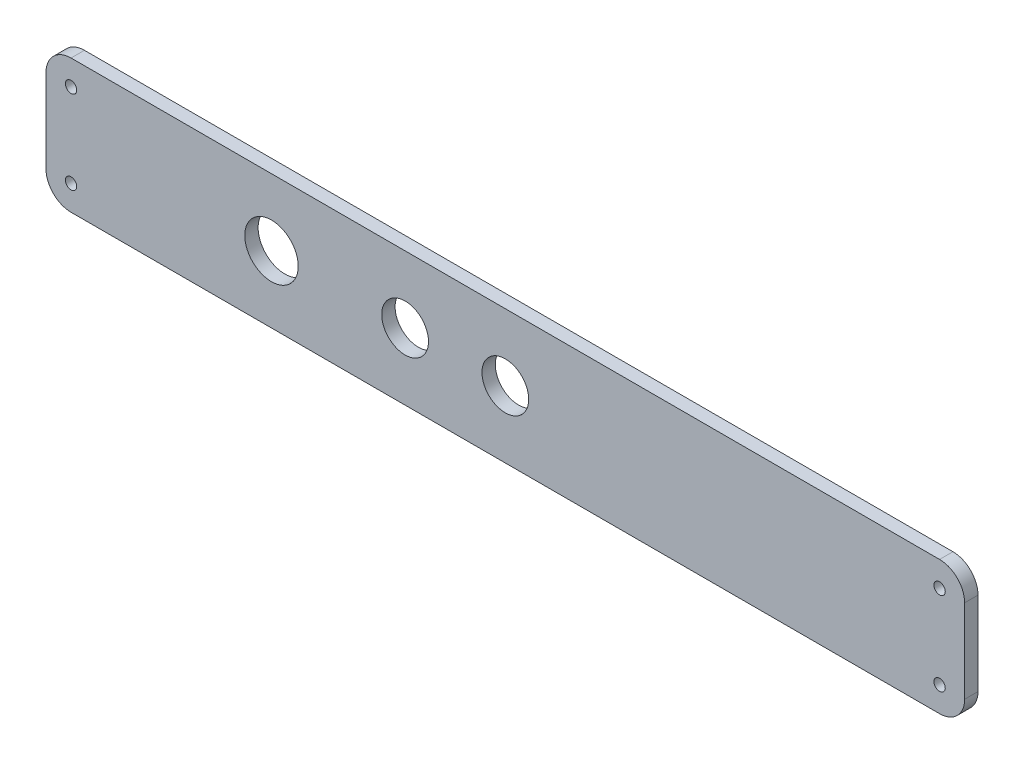
from build123d import *

# Parameters (mm, degrees)
SKETCH_1_W          = 40
SKETCH_1_H          = 275
EXTRUDE_1_DEPTH     = 4
SKETCH_2_R          = 8
SKETCH_2_R_2        = 7
CUT_EXTRUDE_1_DEPTH = 5
HOLE_WIZARD_M3_1_D  = 3.4
FILLET_1_R          = 7.5


with BuildPart() as part:
    # ｽｹｯﾁ1 → ﾎﾞｽ - 押し出し1 (new body)
    with BuildSketch(Plane(origin=(0, 0, 0), x_dir=(0, 1, 0), z_dir=(0, 0, 1))):
        with Locations((20, 137.5)):
            Rectangle(SKETCH_1_W, SKETCH_1_H)
    extrude(amount=EXTRUDE_1_DEPTH)

    # ｽｹｯﾁ2 → ｶｯﾄ - 押し出し1 (cut, through all)
    with BuildSketch(Plane.XY.offset(4)):
        with Locations((-207.5, 20)):
            Circle(SKETCH_2_R)
        with Locations((-167.5, 20)):
            Circle(SKETCH_2_R_2)
        with Locations((-137.5, 20)):
            Circle(SKETCH_2_R_2)
    extrude(amount=-CUT_EXTRUDE_1_DEPTH, mode=Mode.SUBTRACT)

    # M3 すきま穴1 (through all)
    with Locations(Plane.XY.offset(4)):
        with Locations((-267.5, 32.5), (-267.5, 7.5), (-7.5, 7.5), (-7.5, 32.5)):
            Hole(HOLE_WIZARD_M3_1_D / 2)

    # ﾌｨﾚｯﾄ1
    fillet_1_edges = [part.edges().sort_by_distance(p)[0] for p in [
        (-275, 0, 2),
        (-275, 40, 2),
        (0, 40, 2),
        (0, 0, 2),
    ]]
    fillet(fillet_1_edges, radius=FILLET_1_R)


solid = part.part
